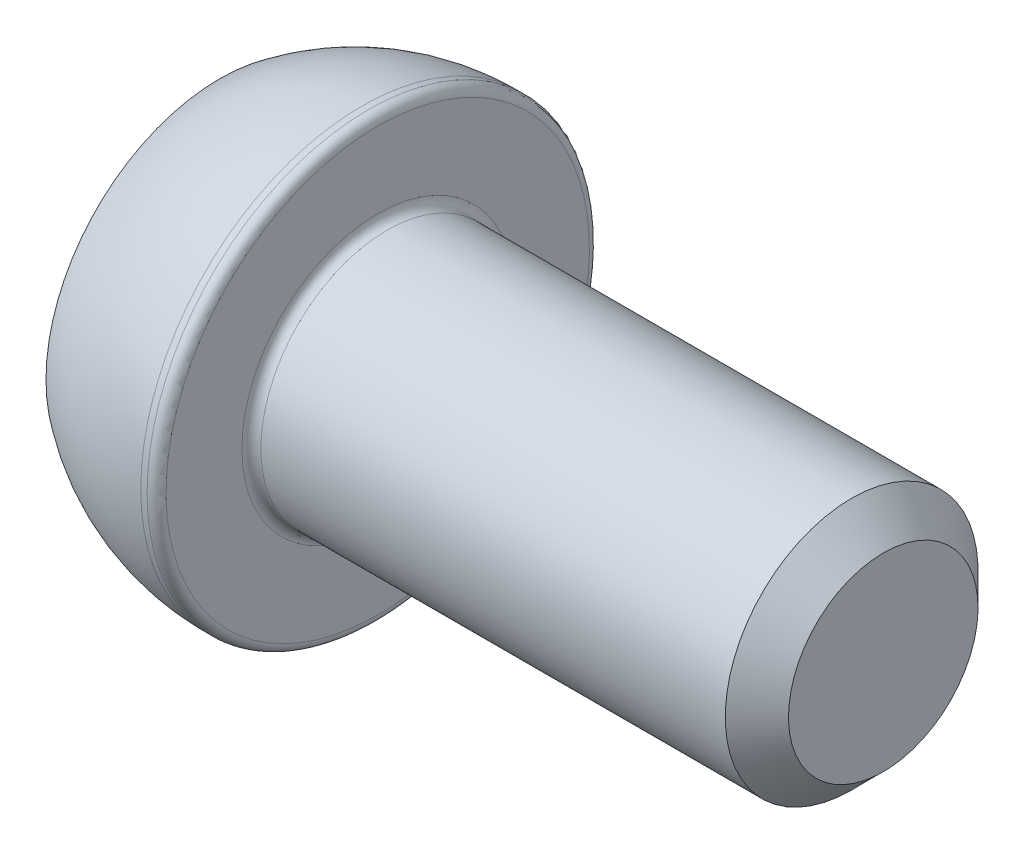
from build123d import *

# Parameters (mm, degrees)
CUT_EXTRUDE_1_DEPTH = 3
FILLET_1_R          = 0.3
CHAMFER_1_SIZE      = 1


with BuildPart() as part:
    # Эскиз1 → Повернуть1 (revolve)
    with BuildSketch(Plane.XY):
        with BuildLine():
            Line((0, 0), (0, 5.5))
            ThreePointArc((0, 5.5), (2.128291755, 6.615124735), (4.5, 7))
            Line((4.5, 7), (5, 7))
            Line((5, 7), (5, 4))
            Line((5, 4), (21, 4))
            Line((21, 4), (21, 0))
            Line((21, 0), (0, 0))
        make_face()
    revolve(axis=Axis((21, 0, 0), (-1, 0, 0)))

    # Эскиз2 → Вырез-Вытянуть1 (cut)
    with BuildSketch(Plane.ZY):
        Polygon((1.732050808, 3), (-1.732050808, 3), (-3.464101615, 0), (-1.732050808, -3), (1.732050808, -3), (3.464101615, 0), align=None)
    extrude(amount=-CUT_EXTRUDE_1_DEPTH, mode=Mode.SUBTRACT)

    # Скругление1
    fillet_1_edges = [part.edges().sort_by_distance(p)[0] for p in [
        (5, -4, 0),
        (5, -7, 0),
    ]]
    fillet(fillet_1_edges, radius=FILLET_1_R)

    # Фаска1
    chamfer_1_edges = [part.edges().sort_by_distance(p)[0] for p in [
        (21, -4, 0),
    ]]
    chamfer(chamfer_1_edges, length=CHAMFER_1_SIZE)


solid = part.part
